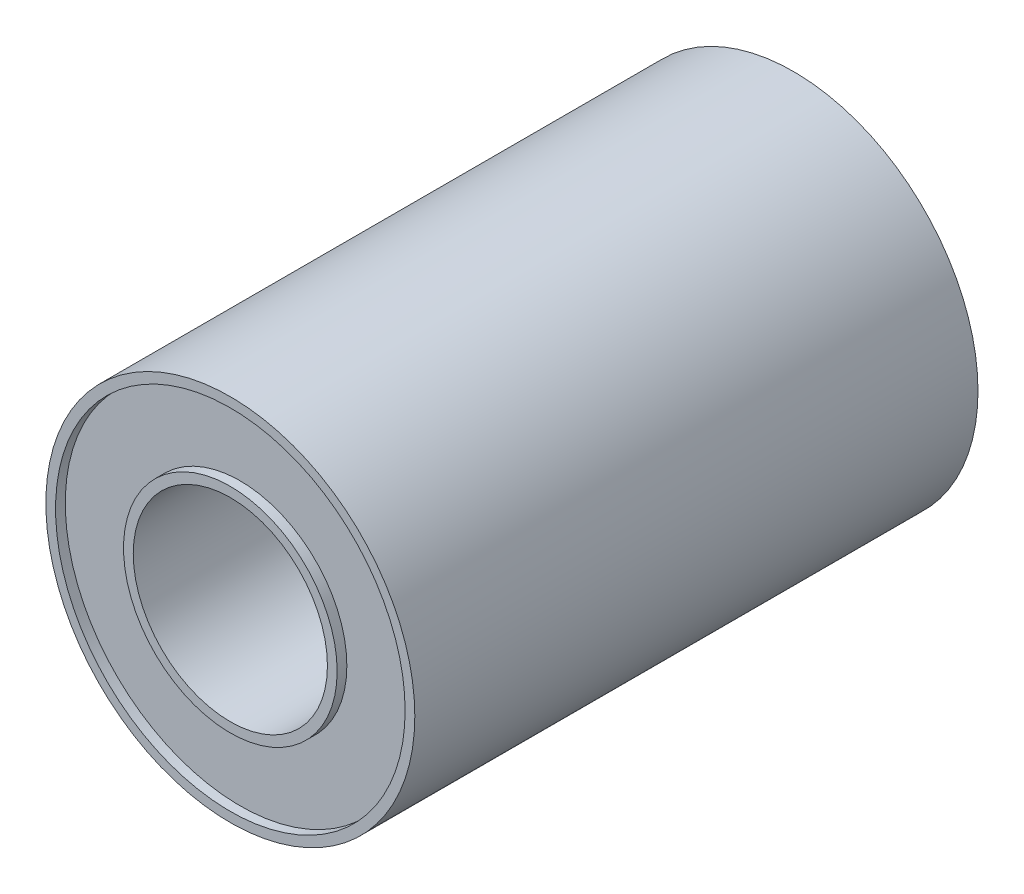
from build123d import *

# Parameters (mm, degrees)
SKIZZE1_R                       = 9.5
SKIZZE1_R_2                     = 5
AUFSATZ_LINEAR_AUSTRAGEN1_DEPTH = 29
SKIZZE2_R                       = 9
SKIZZE2_R_2                     = 5.5
SCHNITT_LINEAR_AUSTRAGEN1_DEPTH = 0.5
SKIZZE3_R                       = 9
SKIZZE3_R_2                     = 5.5
SCHNITT_LINEAR_AUSTRAGEN2_DEPTH = 0.5


with BuildPart() as part:
    # Skizze1 → Aufsatz-Linear austragen1 (new body)
    with BuildSketch(Plane.XY):
        Circle(SKIZZE1_R)
        Circle(SKIZZE1_R_2, mode=Mode.SUBTRACT)
    extrude(amount=-AUFSATZ_LINEAR_AUSTRAGEN1_DEPTH)

    # Skizze2 → Schnitt-Linear austragen1 (cut)
    with BuildSketch(Plane.XY):
        Circle(SKIZZE2_R)
        Circle(SKIZZE2_R_2, mode=Mode.SUBTRACT)
    extrude(amount=-SCHNITT_LINEAR_AUSTRAGEN1_DEPTH, mode=Mode.SUBTRACT)

    # Skizze3 → Schnitt-Linear austragen2 (cut)
    with BuildSketch(Plane(origin=(0, 0, -29), x_dir=(-1, 0, 0), z_dir=(0, 0, -1))):
        Circle(SKIZZE3_R)
        Circle(SKIZZE3_R_2, mode=Mode.SUBTRACT)
    extrude(amount=-SCHNITT_LINEAR_AUSTRAGEN2_DEPTH, mode=Mode.SUBTRACT)


solid = part.part
